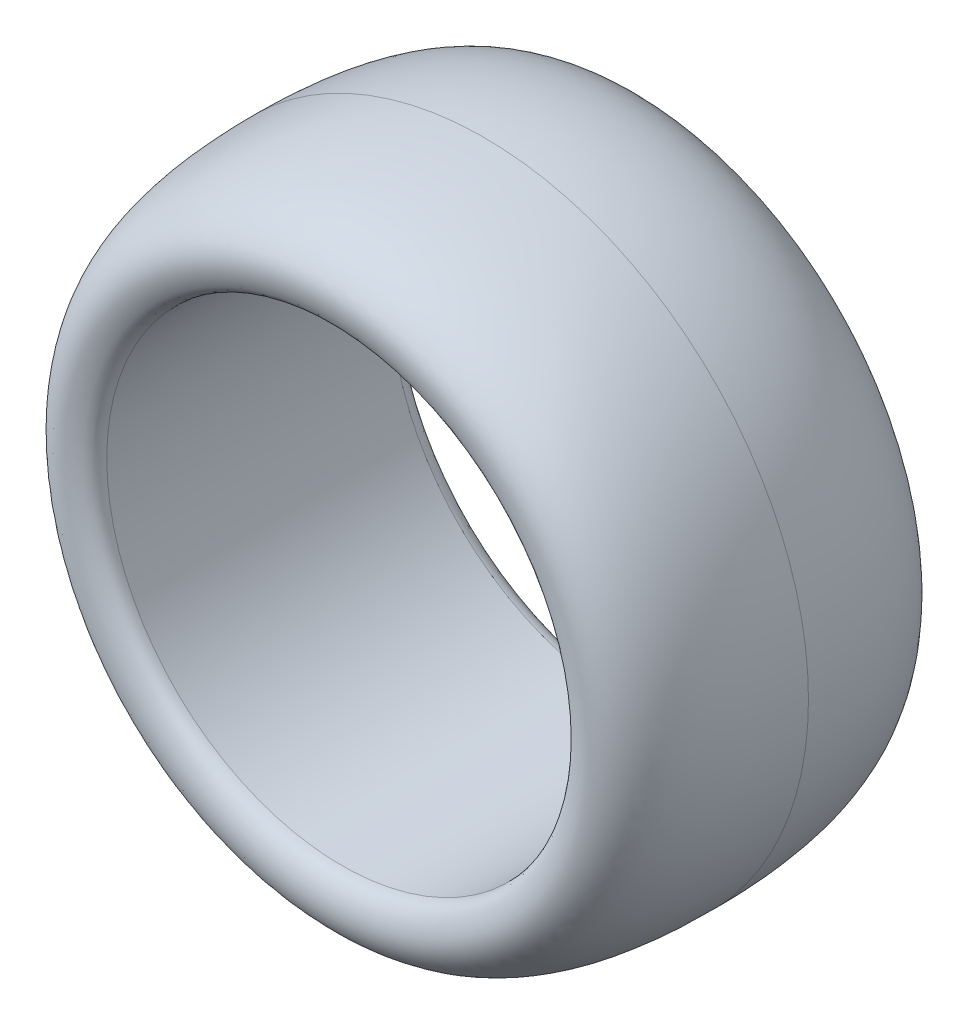
from build123d import *


with BuildPart() as part:
    # Esquisse1 → Révolution1 (revolve)
    with BuildSketch(Plane(origin=(0, 0, 0), x_dir=(0, 0, -1), z_dir=(1, 0, 0))):
        with BuildLine():
            Line((17.5, 29), (-17.5, 29))
            add(Edge.make_bspline(
                [(-17.5, 29), (-18.426270783, 29.106220688), (-19.294580006, 29.506849514), (-20.350146127, 34.407172153), (-16.197562111, 40.021134098), (0, 40)],
                knots=[0, 0, 0, 0, 0.431477054, 0.531477054, 1, 1, 1, 1], degree=3))
            add(Edge.make_bspline(
                [(17.5, 29), (18.426270783, 29.106220688), (19.294580006, 29.506849514), (20.350146127, 34.407172153), (16.197562111, 40.021134098), (0, 40)],
                knots=[0, 0, 0, 0, 0.431477054, 0.531477054, 1, 1, 1, 1], degree=3))
        make_face()
    revolve(axis=Axis((0, 0, 0), (0, 0, -1)))


solid = part.part
